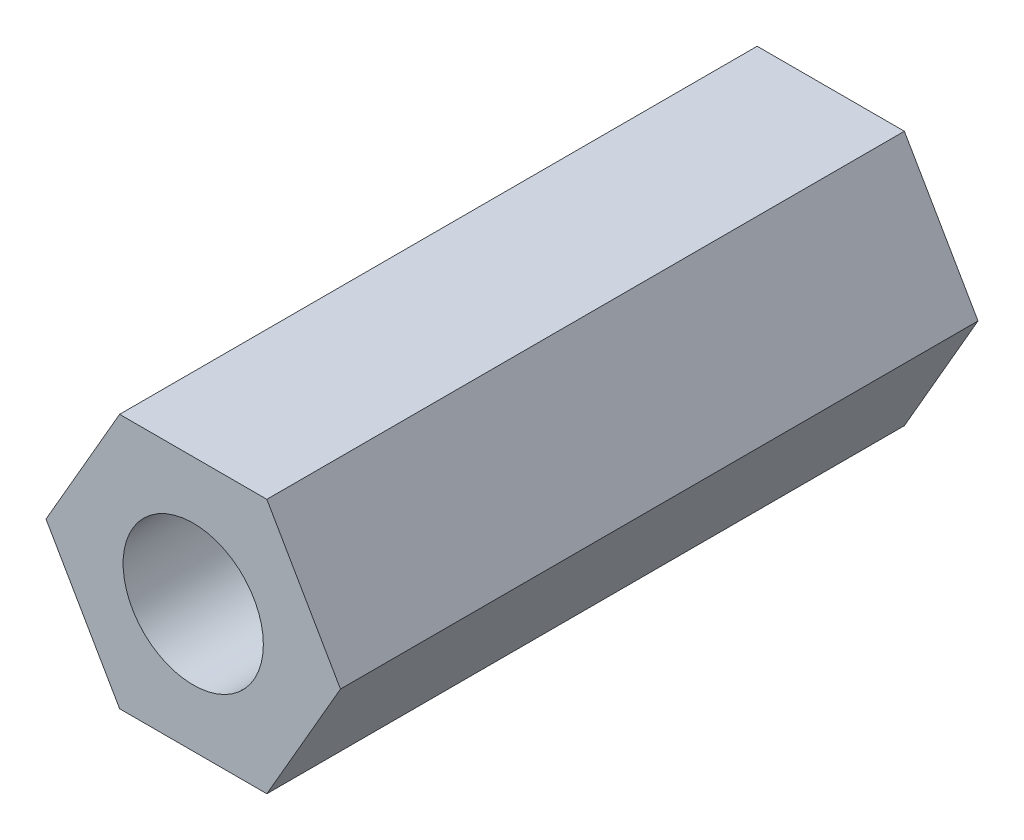
from build123d import *

# Parameters (mm, degrees)
EXTRUDE_1_DEPTH        = 15
HOLE_WIZARD_M4_1_D     = 3.3
HOLE_WIZARD_M4_1_DEPTH = 17.1
HOLE_WIZARD_M4_1_TIP   = 0.991420021


with BuildPart() as part:
    # 草图1 → 凸台-拉伸1 (new body)
    with BuildSketch(Plane.XY):
        Polygon((-1.732050808, 3), (-3.464101615, 0), (-1.732050808, -3), (1.732050808, -3), (3.464101615, 0), (1.732050808, 3), align=None)
    extrude(amount=EXTRUDE_1_DEPTH)

    # M4 螺纹孔1
    with Locations(Plane.XY.offset(15)):
        with Locations((0, 0)):
            Hole(HOLE_WIZARD_M4_1_D / 2, depth=HOLE_WIZARD_M4_1_DEPTH)
            with Locations((0, 0, -(HOLE_WIZARD_M4_1_DEPTH + HOLE_WIZARD_M4_1_TIP / 2))):  # 118° drill point
                Cone(0, HOLE_WIZARD_M4_1_D / 2, HOLE_WIZARD_M4_1_TIP, mode=Mode.SUBTRACT)


solid = part.part
